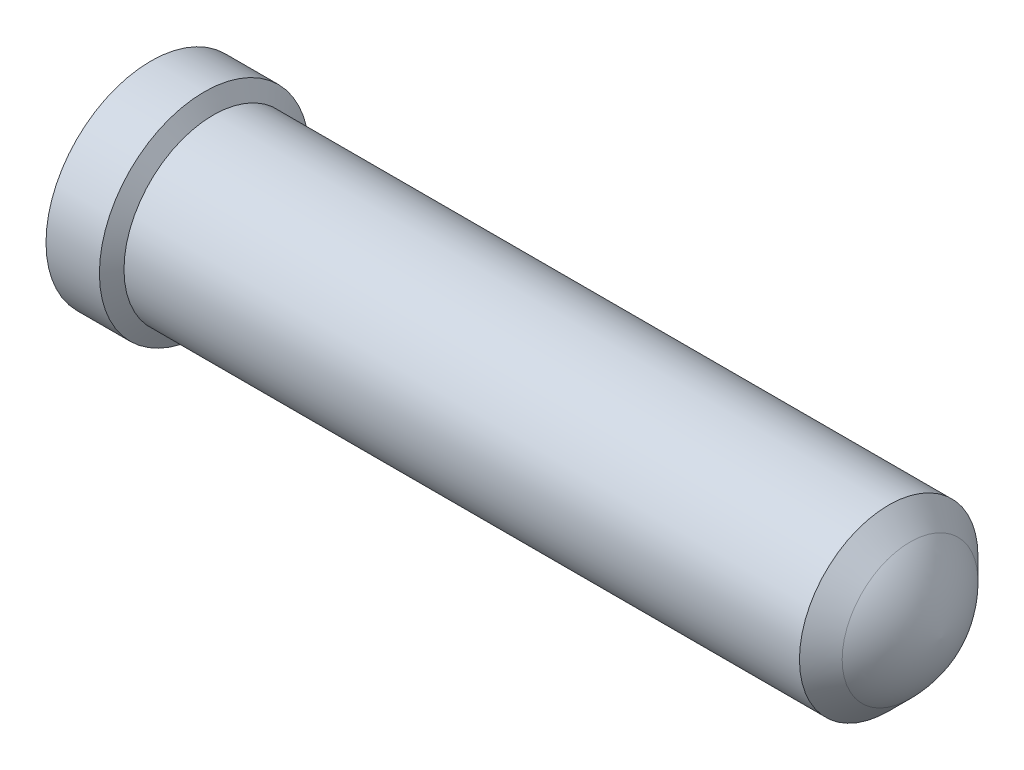
from build123d import *

# Parameters (mm, degrees)
HOLE1_D           = 0.9144
HOLE1_DEPTH       = 2.54
HOLE1_CSINK_D     = 1.0922
HOLE1_CSINK_ANGLE = 90
HOLE1_TIP         = 0.274713475


with BuildPart() as part:
    # Sketch1 → RevolutionAngle1 (revolve)
    with BuildSketch(Plane.XY):
        with BuildLine():
            Line((0, 0), (0, 0.62357))
            Line((0, 0.62357), (0.3175, 0.62357))
            Line((0.3175, 0.62357), (0.371026143, 0.53086))
            Line((0.371026143, 0.53086), (4.387620176, 0.53086))
            Line((4.387620176, 0.53086), (4.514620176, 0.40386))
            ThreePointArc((4.514620176, 0.40386), (4.643254413, 0.218568435), (4.699, 0))
            Line((4.699, 0), (0, 0))
        make_face()
    revolve(axis=Axis((0, 0, 0), (1, 0, 0)))

    # Hole1
    with Locations(Plane.ZY):
        with Locations((0, 0)):
            CounterSinkHole(HOLE1_D / 2, HOLE1_CSINK_D / 2, depth=HOLE1_DEPTH, counter_sink_angle=HOLE1_CSINK_ANGLE)
            with Locations((0, 0, -(HOLE1_DEPTH + HOLE1_TIP / 2))):  # 118° drill point
                Cone(0, HOLE1_D / 2, HOLE1_TIP, mode=Mode.SUBTRACT)


solid = part.part
